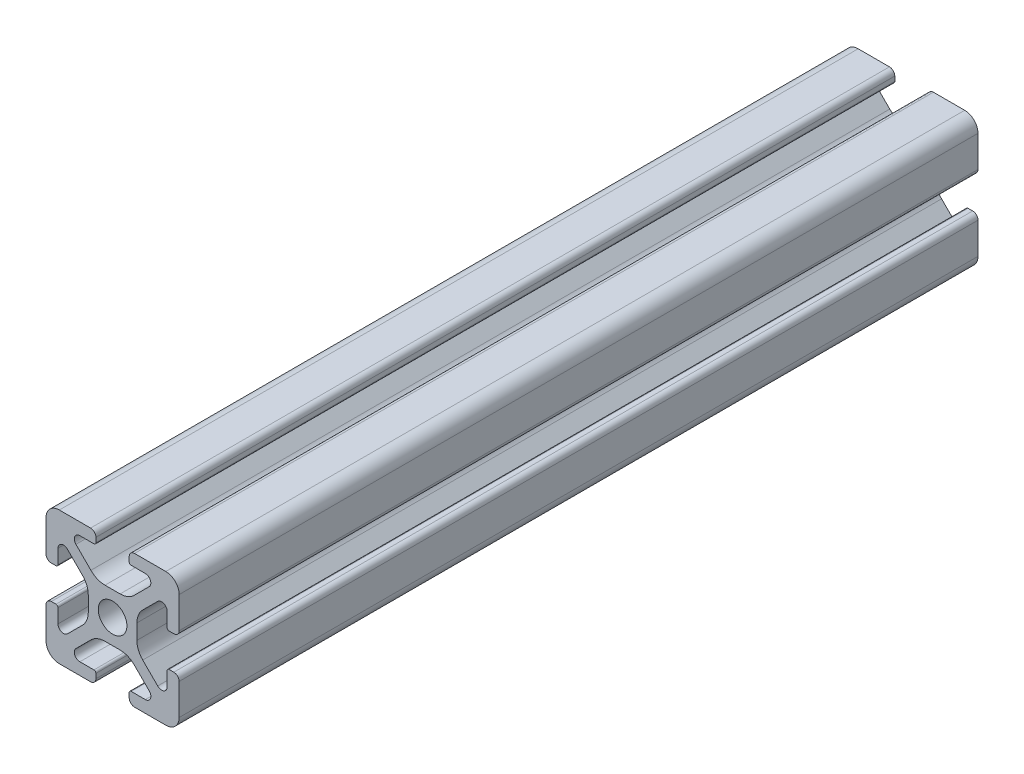
from build123d import *

# Parameters (mm, degrees)
SKETCH4_W              = 20
SKETCH4_H              = 20
BODY_DEPTH             = 120
SKETCH16_OUTSIDE_W     = 46.658
SKETCH16_OUTSIDE_H     = 46.658
SKETCH16_OUTSIDE_R     = 2.15
CUT_PROFILE_DEPTH      = 26
CUT_PROFILE_DEPTH_BACK = 96


with BuildPart() as part:
    # Sketch4 → Body (new body)
    with BuildSketch(Plane.XY.offset(25)):
        Rectangle(SKETCH4_W, SKETCH4_H)
    extrude(amount=-BODY_DEPTH)

    # Sketch16 outside → Cut-Profile (cut, two sides)
    with BuildSketch(Plane.XY) as cut_profile_sk:
        Rectangle(SKETCH16_OUTSIDE_W, SKETCH16_OUTSIDE_H)
        with BuildLine():
            Line((4.917588389, -8.199999991), (2.799999989, -8.199999991))
            ThreePointArc((2.799999989, -8.199999991), (2.587867955, -8.287867957), (2.499999989, -8.499999991))
            Line((2.499999989, -8.499999991), (2.499999989, -9.199999991))
            ThreePointArc((2.499999989, -9.199999991), (2.734314564, -9.765685416), (3.299999989, -9.999999991))
            Line((3.299999989, -9.999999991), (7.999999989, -9.999999991))
            ThreePointArc((7.999999989, -9.999999991), (9.414213552, -9.414213554), (9.999999989, -7.999999991))
            Line((9.999999989, -7.999999991), (9.999999989, -3.299999991))
            ThreePointArc((9.999999989, -3.299999991), (9.765685414, -2.734314566), (9.199999989, -2.499999991))
            Line((9.199999989, -2.499999991), (8.499999989, -2.499999991))
            ThreePointArc((8.499999989, -2.499999991), (8.287867955, -2.587867957), (8.199999989, -2.799999991))
            Line((8.199999989, -2.799999991), (8.199999989, -4.917588391))
            ThreePointArc((8.199999989, -4.917588391), (7.686138511, -5.686636441), (6.778984485, -5.506192286))
            Line((6.778984485, -5.506192286), (4.528679645, -3.255887446))
            ThreePointArc((4.528679645, -3.255887446), (3.878361392, -2.282617401), (3.64999999, -1.134567106))
            Line((3.64999999, -1.134567106), (3.64999999, 1.134567104))
            ThreePointArc((3.64999999, 1.134567104), (3.878361393, 2.282617402), (4.528679647, 3.255887448))
            Line((4.528679647, 3.255887448), (6.778984487, 5.506192288))
            ThreePointArc((6.778984487, 5.506192288), (7.686138506, 5.686636442), (8.199999981, 4.917588398))
            Line((8.199999981, 4.917588398), (8.199999981, 2.799999998))
            ThreePointArc((8.199999981, 2.799999998), (8.287867946, 2.587867964), (8.499999981, 2.499999998))
            Line((8.499999981, 2.499999998), (9.199999981, 2.499999998))
            ThreePointArc((9.199999981, 2.499999998), (9.765685406, 2.734314573), (9.999999981, 3.299999998))
            Line((9.999999981, 3.299999998), (9.999999981, 7.999999998))
            ThreePointArc((9.999999981, 7.999999998), (9.414213543, 9.41421356), (7.999999981, 9.999999998))
            Line((7.999999981, 9.999999998), (3.299999981, 9.999999998))
            ThreePointArc((3.299999981, 9.999999998), (2.734314556, 9.765685423), (2.499999981, 9.199999998))
            Line((2.499999981, 9.199999998), (2.499999981, 8.499999998))
            ThreePointArc((2.499999981, 8.499999998), (2.587867946, 8.287867964), (2.799999981, 8.199999998))
            Line((2.799999981, 8.199999998), (4.917588381, 8.199999998))
            ThreePointArc((4.917588381, 8.199999998), (5.68663643, 7.68613852), (5.506192275, 6.778984494))
            Line((5.506192275, 6.778984494), (3.255887435, 4.528679654))
            ThreePointArc((3.255887435, 4.528679654), (2.28261739, 3.878361401), (1.134567095, 3.649999999))
            Line((1.134567095, 3.649999999), (-1.134567115, 3.649999999))
            ThreePointArc((-1.134567115, 3.649999999), (-2.282617412, 3.878361401), (-3.255887459, 4.528679655))
            Line((-3.255887459, 4.528679655), (-5.506192299, 6.778984495))
            ThreePointArc((-5.506192299, 6.778984495), (-5.686636452, 7.686138515), (-4.917588409, 8.199999989))
            Line((-4.917588409, 8.199999989), (-2.800000009, 8.199999989))
            ThreePointArc((-2.800000009, 8.199999989), (-2.587867974, 8.287867955), (-2.500000009, 8.499999989))
            Line((-2.500000009, 8.499999989), (-2.500000009, 9.199999989))
            ThreePointArc((-2.500000009, 9.199999989), (-2.734314584, 9.765685414), (-3.300000009, 9.999999989))
            Line((-3.300000009, 9.999999989), (-8.000000009, 9.999999989))
            ThreePointArc((-8.000000009, 9.999999989), (-9.414213571, 9.414213552), (-10.000000009, 7.999999989))
            Line((-10.000000009, 7.999999989), (-10.000000009, 3.299999989))
            ThreePointArc((-10.000000009, 3.299999989), (-9.765685434, 2.734314564), (-9.200000009, 2.499999989))
            Line((-9.200000009, 2.499999989), (-8.500000009, 2.499999989))
            ThreePointArc((-8.500000009, 2.499999989), (-8.287867974, 2.587867955), (-8.200000009, 2.799999989))
            Line((-8.200000009, 2.799999989), (-8.200000009, 4.917588389))
            ThreePointArc((-8.200000009, 4.917588389), (-7.686138531, 5.686636438), (-6.778984504, 5.506192284))
            Line((-6.778984504, 5.506192284), (-4.528679664, 3.255887444))
            ThreePointArc((-4.528679664, 3.255887444), (-3.878361412, 2.282617399), (-3.650000009, 1.134567104))
            Line((-3.650000009, 1.134567104), (-3.650000009, -1.134567106))
            ThreePointArc((-3.650000009, -1.134567106), (-3.878361412, -2.282617404), (-4.528679666, -3.25588745))
            Line((-4.528679666, -3.25588745), (-6.778984506, -5.50619229))
            ThreePointArc((-6.778984506, -5.50619229), (-7.686138526, -5.686636444), (-8.2, -4.9175884))
            Line((-8.2, -4.9175884), (-8.2, -2.8))
            ThreePointArc((-8.2, -2.8), (-8.287867966, -2.587867966), (-8.5, -2.5))
            Line((-8.5, -2.5), (-9.2, -2.5))
            ThreePointArc((-9.2, -2.5), (-9.765685425, -2.734314575), (-10, -3.3))
            Line((-10, -3.3), (-10, -8))
            ThreePointArc((-10, -8), (-9.414213562, -9.414213562), (-8, -10))
            Line((-8, -10), (-3.3, -10))
            ThreePointArc((-3.3, -10), (-2.734314575, -9.765685425), (-2.5, -9.2))
            Line((-2.5, -9.2), (-2.5, -8.5))
            ThreePointArc((-2.5, -8.5), (-2.587867966, -8.287867966), (-2.8, -8.2))
            Line((-2.8, -8.2), (-4.9175884, -8.2))
            ThreePointArc((-4.9175884, -8.2), (-5.686636449, -7.686138522), (-5.506192294, -6.778984496))
            Line((-5.506192294, -6.778984496), (-3.255887454, -4.528679656))
            ThreePointArc((-3.255887454, -4.528679656), (-2.282617409, -3.878361403), (-1.134567114, -3.650000001))
            Line((-1.134567114, -3.650000001), (1.134567096, -3.650000001))
            ThreePointArc((1.134567096, -3.650000001), (2.282617393, -3.878361403), (3.255887439, -4.528679657))
            Line((3.255887439, -4.528679657), (5.506192279, -6.778984497))
            ThreePointArc((5.506192279, -6.778984497), (5.686636433, -7.686138517), (4.917588389, -8.199999991))
        make_face(mode=Mode.SUBTRACT)
        Circle(SKETCH16_OUTSIDE_R)
    extrude(amount=CUT_PROFILE_DEPTH, mode=Mode.SUBTRACT)
    extrude(cut_profile_sk.sketch, amount=-CUT_PROFILE_DEPTH_BACK, mode=Mode.SUBTRACT)


solid = part.part
